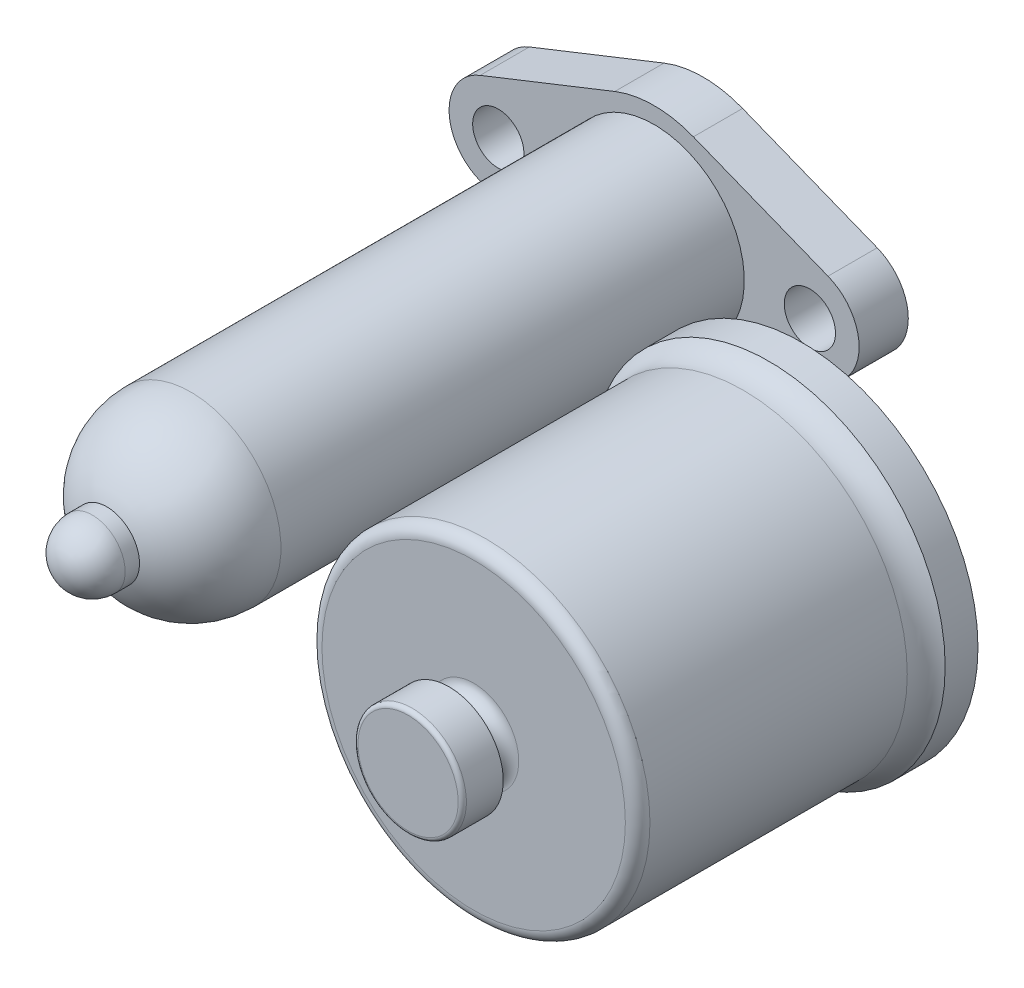
from build123d import *

# Parameters (mm, degrees)
BOSS_EXTRUDE1_DEPTH = 12
SKETCH7_R           = 6.25
SKETCH7_R_2         = 16
CUT_EXTRUDE2_DEPTH  = 32
SKETCH11_R          = 2
CUT_EXTRUDE3_DEPTH  = 8
CIRPATTERN6_COUNT   = 4


with BuildPart() as part:
    # Sketch1 → Revolve1 (revolve)
    with BuildSketch(Plane(origin=(0, 0, 0), x_dir=(1, 0, 0), z_dir=(0, 1, 0)), mode=Mode.PRIVATE) as revolve1_sk:
        with BuildLine():
            Line((22, 113), (22, 0))
            ThreePointArc((22, 0), (18.165902125, -12.409673646), (8, -20.493901532))
            Line((8, -20.493901532), (8, -24))
            ThreePointArc((8, -24), (5.656854249, -29.656854249), (0, -32))
            Line((0, -32), (0, -28.805922308))
            Line((0, -28.805922308), (4.86, -26))
            Line((4.86, -26), (4.86, -15.244028339))
            ThreePointArc((4.86, -15.244028339), (12.91820421, -9.440338977), (16, 0))
            Line((16, 0), (16, 113))
            Line((16, 113), (22, 113))
        make_face()
    revolve(revolve1_sk.sketch.rotate(Axis((0, 0, -39.832584558), (0, 0, 1)), 180), axis=Axis((0, 0, -39.832584558), (0, 0, 1)))

    # Sketch4 → Boss-Extrude1 (add)
    with BuildSketch(Plane(origin=(0, 0, -113), x_dir=(-1, 0, 0), z_dir=(0, 0, -1))):
        with BuildLine():
            Line((-42.421052632, 11.155908463), (-9.578947368, 24.171135003))
            ThreePointArc((-9.578947368, 24.171135003), (0, 26), (9.578947368, 24.171135003))
            Line((9.578947368, 24.171135003), (42.421052632, 11.155908463))
            ThreePointArc((42.421052632, 11.155908463), (50, 0), (42.421052632, -11.155908463))
            Line((42.421052632, -11.155908463), (9.578947368, -24.171135003))
            ThreePointArc((9.578947368, -24.171135003), (0, -26), (-9.578947368, -24.171135003))
            Line((-9.578947368, -24.171135003), (-42.421052632, -11.155908463))
            ThreePointArc((-42.421052632, -11.155908463), (-50, 0), (-42.421052632, 11.155908463))
        make_face()
    extrude(amount=BOSS_EXTRUDE1_DEPTH)

    # Sketch7 → Cut-Extrude2 (cut)
    with BuildSketch(Plane(origin=(0, 0, -125), x_dir=(-1, 0, 0), z_dir=(0, 0, -1))):
        with Locations((38, 0)):
            Circle(SKETCH7_R)
        Circle(SKETCH7_R_2)
        with Locations((-38, 0)):
            Circle(SKETCH7_R)
    extrude(amount=-CUT_EXTRUDE2_DEPTH, mode=Mode.SUBTRACT)


with BuildPart() as body_2:
    # Sketch2 → Revolve2 (revolve)
    with BuildSketch(Plane(origin=(0, 0, 0), x_dir=(1, 0, 0), z_dir=(0, 1, 0)), mode=Mode.PRIVATE) as revolve2_sk:
        with BuildLine():
            Line((128, 64), (128, 56))
            ThreePointArc((128, 56), (125.788897449, 53.219103617), (125, 49.755002002))
            Line((125, 49.755002002), (125, -13))
            ThreePointArc((125, -13), (124.121320344, -15.121320344), (122, -16))
            Line((122, -16), (96, -16))
            ThreePointArc((96, -16), (93.878679656, -16.878679656), (93, -19))
            Line((93, -19), (93, -22))
            Line((93, -22), (98.2205, -22))
            Line((98.2205, -22), (98.2205, -31))
            ThreePointArc((98.2205, -31), (97.927606781, -31.707106781), (97.2205, -32))
            Line((97.2205, -32), (85, -32))
            Line((85, -32), (85, -23))
            Line((85, -23), (86.5, -23))
            Line((86.5, -23), (86.5, -14.330127019))
            Line((86.5, -14.330127019), (89, -10))
            Line((89, -10), (89, 4))
            Line((89, 4), (91.491397174, 4))
            ThreePointArc((91.491397174, 4), (92.695788201, 3.596697296), (93.41444507, 2.549442256))
            Line((93.41444507, 2.549442256), (96.58555493, -8.549442256))
            ThreePointArc((96.58555493, -8.549442256), (97.304211799, -9.596697296), (98.508602826, -10))
            Line((98.508602826, -10), (118, -10))
            ThreePointArc((118, -10), (118.707106781, -9.707106781), (119, -9))
            Line((119, -9), (119, 64))
            Line((119, 64), (128, 64))
        make_face()
    revolve(revolve2_sk.sketch.rotate(Axis((85, 0, -126.772662803), (0, 0, 1)), 180), axis=Axis((85, 0, -126.772662803), (0, 0, 1)))

    # Sketch11 → Cut-Extrude3 (cut)
    with BuildSketch(Plane(origin=(0, 0, -64), x_dir=(-1, 0, 0), z_dir=(0, 0, -1))):
        with Locations((-123, 0)):
            Circle(SKETCH11_R)
    cut_extrude3 = extrude(amount=-CUT_EXTRUDE3_DEPTH, mode=Mode.SUBTRACT)

    # CirPattern6: Cut-Extrude3 ×4 about axis
    cirpattern6_axis = Axis((85, 0, 0), (0, 0, 1))
    for i in range(1, CIRPATTERN6_COUNT):
        add(cut_extrude3.rotate(cirpattern6_axis, i * 360 / CIRPATTERN6_COUNT), mode=Mode.SUBTRACT)


solid = Compound([part.part, body_2.part])
